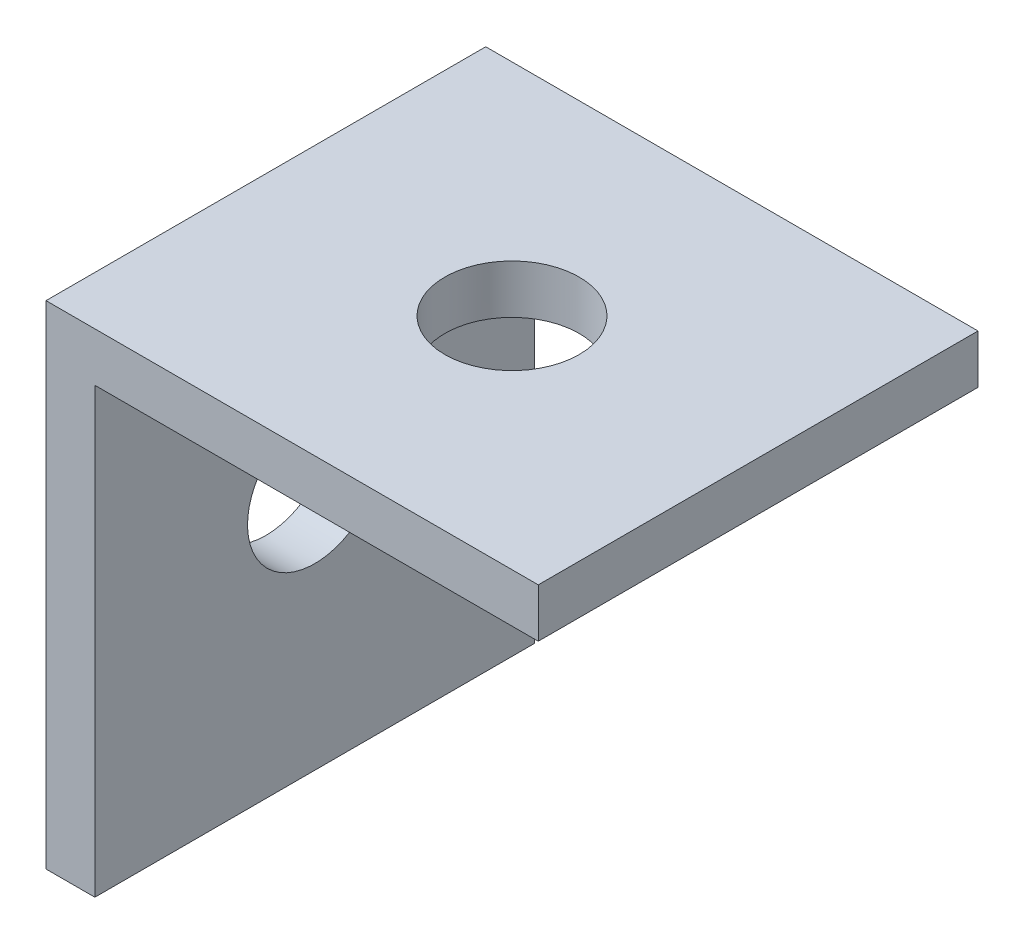
from build123d import *

# Parameters (mm, degrees)
BOSS_EXTRUDE1_DEPTH = 18
SKETCH2_R           = 2.75
CUT_EXTRUDE1_DEPTH  = 18
SKETCH3_R           = 2.75
CUT_EXTRUDE2_DEPTH  = 18


with BuildPart() as part:
    # Sketch1 → Boss-Extrude1 (new body)
    with BuildSketch(Plane.XY):
        Polygon((0, 0), (0, -20.15), (2, -20.15), (2, -2), (20.15, -2), (20.15, 0), align=None)
    extrude(amount=-BOSS_EXTRUDE1_DEPTH)

    # Sketch2 → Cut-Extrude1 (cut)
    with BuildSketch(Plane.XZ.offset(2)):
        with Locations((10.075, -9)):
            Circle(SKETCH2_R)
    extrude(amount=-CUT_EXTRUDE1_DEPTH, mode=Mode.SUBTRACT)

    # Sketch3 → Cut-Extrude2 (cut)
    with BuildSketch(Plane(origin=(2, 0, 0), x_dir=(0, 0, -1), z_dir=(1, 0, 0))):
        with Locations((9, -10.075)):
            Circle(SKETCH3_R)
    extrude(amount=-CUT_EXTRUDE2_DEPTH, mode=Mode.SUBTRACT)


solid = part.part
